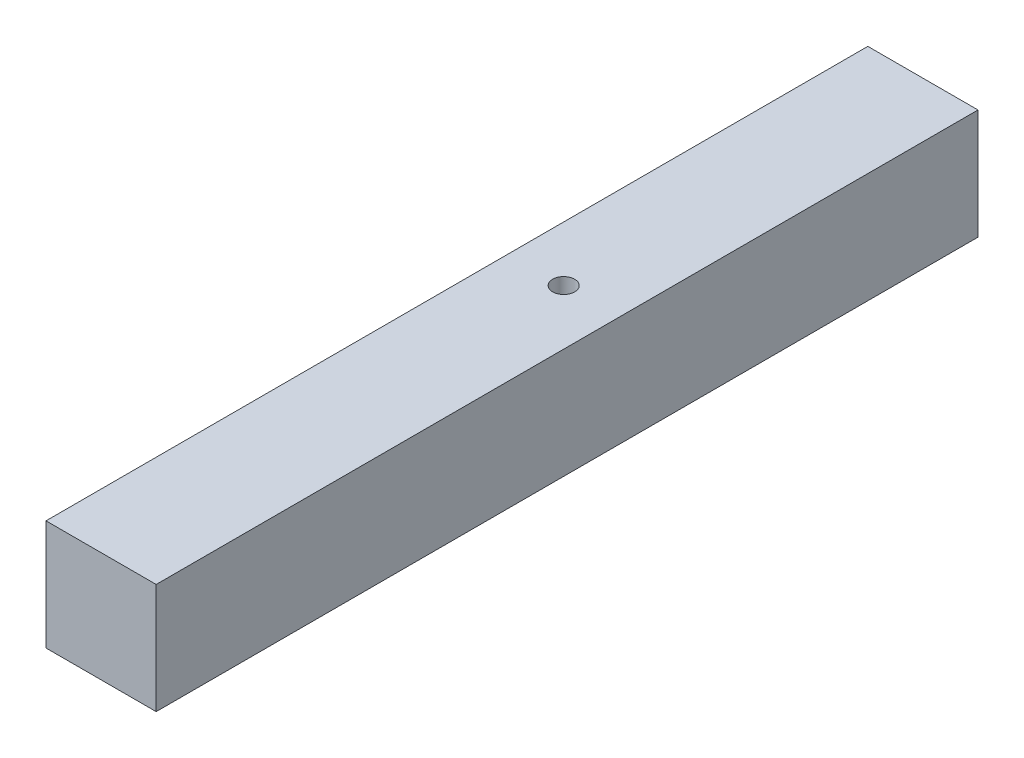
from build123d import *

# Parameters (mm, degrees)
SKETCH1_W           = 20
SKETCH1_H           = 20
BOSS_EXTRUDE1_DEPTH = 149.19
SKETCH2_R           = 2
CUT_EXTRUDE1_DEPTH  = 21


with BuildPart() as part:
    # Sketch1 → Boss-Extrude1 (new body)
    with BuildSketch(Plane.XY):
        with Locations((10, 10)):
            Rectangle(SKETCH1_W, SKETCH1_H)
    extrude(amount=BOSS_EXTRUDE1_DEPTH)

    # Sketch2 → Cut-Extrude1 (cut, through all)
    with BuildSketch(Plane(origin=(0, 20, 0), x_dir=(1, 0, 0), z_dir=(0, 1, 0))):
        with Locations((10, -65.214474091)):
            Circle(SKETCH2_R)
    extrude(amount=-CUT_EXTRUDE1_DEPTH, mode=Mode.SUBTRACT)


solid = part.part
